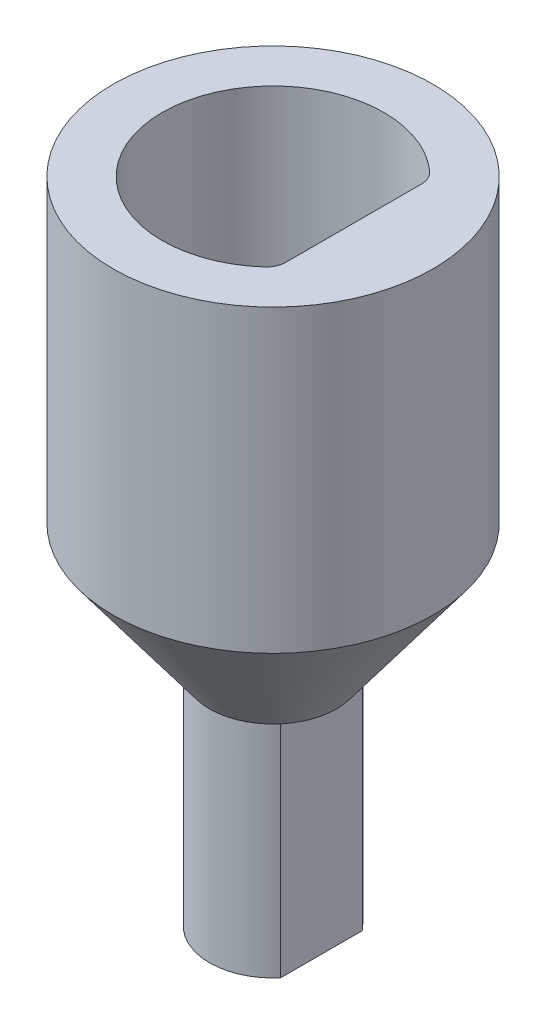
from build123d import *

# Parameters (mm, degrees)
SKETCH1_R               = 8
BOSS_EXTRUDE1_DEPTH     = 10
CUT_EXTRUDE1_DEPTH      = 12
CUT_EXTRUDE1_DEPTH_BACK = 12
SKETCH3_W               = 0.75
SKETCH3_H               = 11
FILLET2_R               = 1
FILLET3_R               = 1


with BuildPart() as part:
    # Sketch1 → Boss-Extrude1 (new body)
    with BuildSketch(Plane(origin=(0, 0, 0), x_dir=(1, 0, 0), z_dir=(0, 1, 0))):
        Circle(SKETCH1_R)
        with BuildLine():
            Line((4.036363636, -0.000130644), (4.036363636, 3.809234647))
            ThreePointArc((4.036363636, 3.809234647), (-5.55, 0), (4.036363636, -3.809234647))
            Line((4.036363636, -3.809234647), (4.036363636, -0.000130644))
        make_face(mode=Mode.SUBTRACT)
    extrude(amount=BOSS_EXTRUDE1_DEPTH)

    # Sketch2 → Revolve1 (revolve)
    with BuildSketch(Plane.XY):
        Polygon((8, 0), (8, -5), (3.175, -11.473666382), (3.175, -22.473666382), (0, -22.473666382), (0, 0), align=None)
    revolve(axis=Axis((0, -22.473666382, 0), (0, -1, 0)))

    # Sketch3 → Cut-Extrude1 (cut, two sides: drawn at the far end of the back side and taken through both)
    with BuildSketch(Plane.XY.offset(-CUT_EXTRUDE1_DEPTH_BACK)):
        with Locations((2.8, -16.973666382)):
            Rectangle(SKETCH3_W, SKETCH3_H)
    extrude(amount=CUT_EXTRUDE1_DEPTH + CUT_EXTRUDE1_DEPTH_BACK, mode=Mode.SUBTRACT)

    # Fillet2
    fillet2_edges = [part.edges().sort_by_distance(p)[0] for p in [
        (4.036363636, 5, -3.809234647),
    ]]
    fillet(fillet2_edges, radius=FILLET2_R)

    # Fillet3
    fillet3_edges = [part.edges().sort_by_distance(p)[0] for p in [
        (4.036363636, 5, 3.809234647),
    ]]
    fillet(fillet3_edges, radius=FILLET3_R)


solid = part.part
